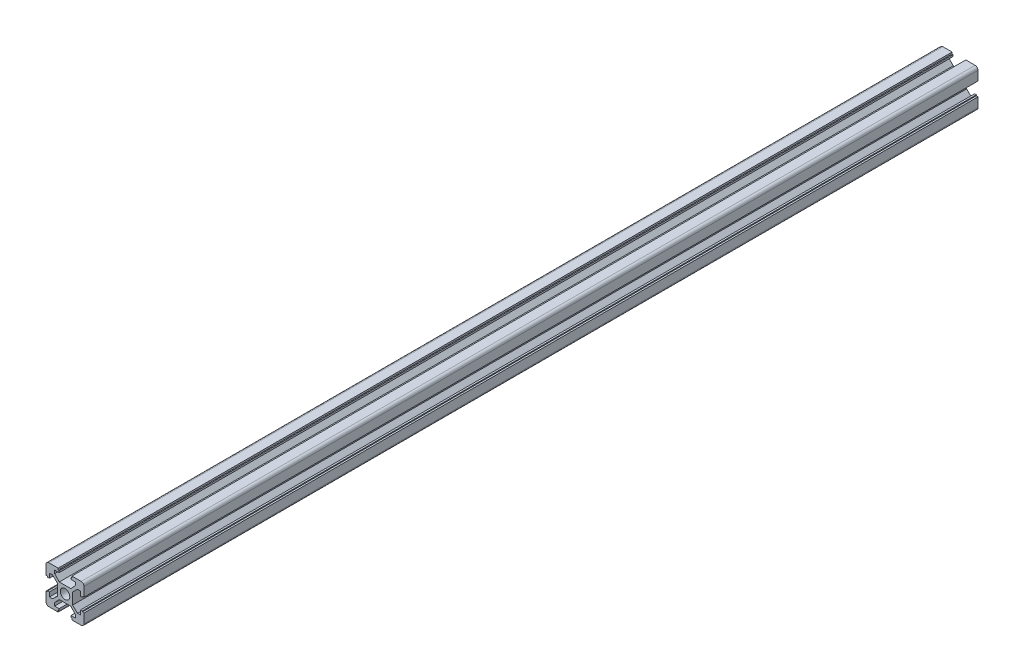
from build123d import *

# Parameters (mm, degrees)
SKETCH_1_R      = 2.5
EXTRUDE_1_DEPTH = 470
FILLET_1_R      = 1.5


with BuildPart() as part:
    # 草图1 → 凸台-拉伸1 (new body)
    with BuildSketch(Plane.XY):
        Polygon((-3.012509258, 4), (3.012509258, 4), (5.45, 6.584741199), (5.45, 8.2), (3.1, 8.2), (3.1, 9.1), (3.6, 9.1), (3.6, 10), (10, 10), (10, 3.6), (9.1, 3.6), (9.1, 3.1), (8.2, 3.1), (8.2, 5.45), (6.584741199, 5.45), (4, 3.012509258), (4, -3.012509258), (6.584741199, -5.45), (8.2, -5.45), (8.2, -3.1), (9.1, -3.1), (9.1, -3.6), (10, -3.6), (10, -10), (3.6, -10), (3.6, -9.1), (3.1, -9.1), (3.1, -8.2), (5.45, -8.2), (5.45, -6.584741199), (3.012509258, -4), (-3.012509258, -4), (-5.45, -6.584741199), (-5.45, -8.2), (-3.1, -8.2), (-3.1, -9.1), (-3.6, -9.1), (-3.6, -10), (-10, -10), (-10, -3.6), (-9.1, -3.6), (-9.1, -3.1), (-8.2, -3.1), (-8.2, -5.45), (-6.584741199, -5.45), (-4, -3.012509258), (-4, 3.012509258), (-6.584741199, 5.45), (-8.2, 5.45), (-8.2, 3.1), (-9.1, 3.1), (-9.1, 3.6), (-10, 3.6), (-10, 10), (-3.6, 10), (-3.6, 9.1), (-3.1, 9.1), (-3.1, 8.2), (-5.45, 8.2), (-5.45, 6.584741199), align=None)
        Circle(SKETCH_1_R, mode=Mode.SUBTRACT)
    extrude(amount=EXTRUDE_1_DEPTH)

    # 圆角1
    fillet_1_edges = [part.edges().sort_by_distance(p)[0] for p in [
        (10, -10, 235),
        (-10, -10, 235),
        (-10, 10, 235),
        (10, 10, 235),
    ]]
    fillet(fillet_1_edges, radius=FILLET_1_R)


solid = part.part
